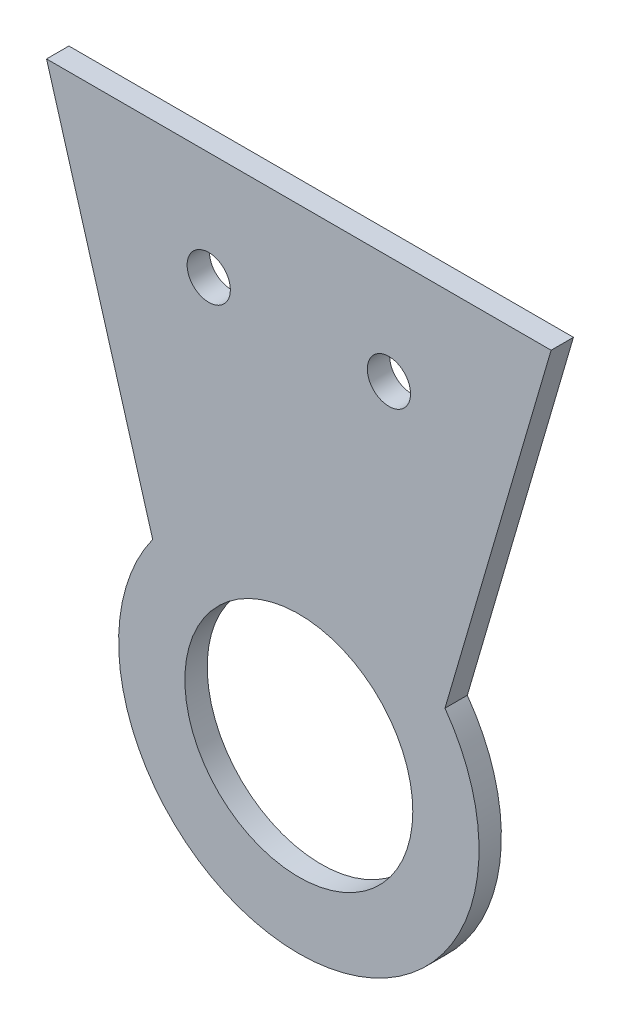
from build123d import *

# Parameters (mm, degrees)
SKETCH1_W               = 70
SKETCH1_H               = 100
SKETCH1_R               = 15.8115
SKETCH1_R_2             = 3
BOSS_EXTRUDE1_DEPTH     = 3.1
CUT_EXTRUDE1_DEPTH      = 1
CUT_EXTRUDE1_DEPTH_BACK = 4.1


with BuildPart() as part:
    # Sketch1 → Boss-Extrude1 (new body)
    with BuildSketch(Plane.XY):
        with Locations((0, 15)):
            Rectangle(SKETCH1_W, SKETCH1_H)
        Circle(SKETCH1_R, mode=Mode.SUBTRACT)
        with Locations((-12.5, 50)):
            Circle(SKETCH1_R_2, mode=Mode.SUBTRACT)
        with Locations((12.5, 50)):
            Circle(SKETCH1_R_2, mode=Mode.SUBTRACT)
    extrude(amount=BOSS_EXTRUDE1_DEPTH)

    # Sketch2 → Cut-Extrude1 (cut, two sides)
    with BuildSketch(Plane.XY.offset(3.1)) as cut_extrude1_sk:
        with BuildLine():
            Line((-106.300801708, 308.923795317), (-35, 65))
            Line((-35, 65), (-20.275240011, 14.625821089))
            ThreePointArc((-20.275240011, 14.625821089), (0, -25), (20.275240011, 14.625821089))
            Line((20.275240011, 14.625821089), (35, 65))
            Line((35, 65), (106.300801708, 308.923795317))
            Line((106.300801708, 308.923795317), (106.300801708, -199.338429312))
            Line((106.300801708, -199.338429312), (-106.300801708, -199.338429312))
            Line((-106.300801708, -199.338429312), (-106.300801708, 308.923795317))
        make_face()
    extrude(amount=CUT_EXTRUDE1_DEPTH, mode=Mode.SUBTRACT)
    extrude(cut_extrude1_sk.sketch, amount=-CUT_EXTRUDE1_DEPTH_BACK, mode=Mode.SUBTRACT)


solid = part.part
